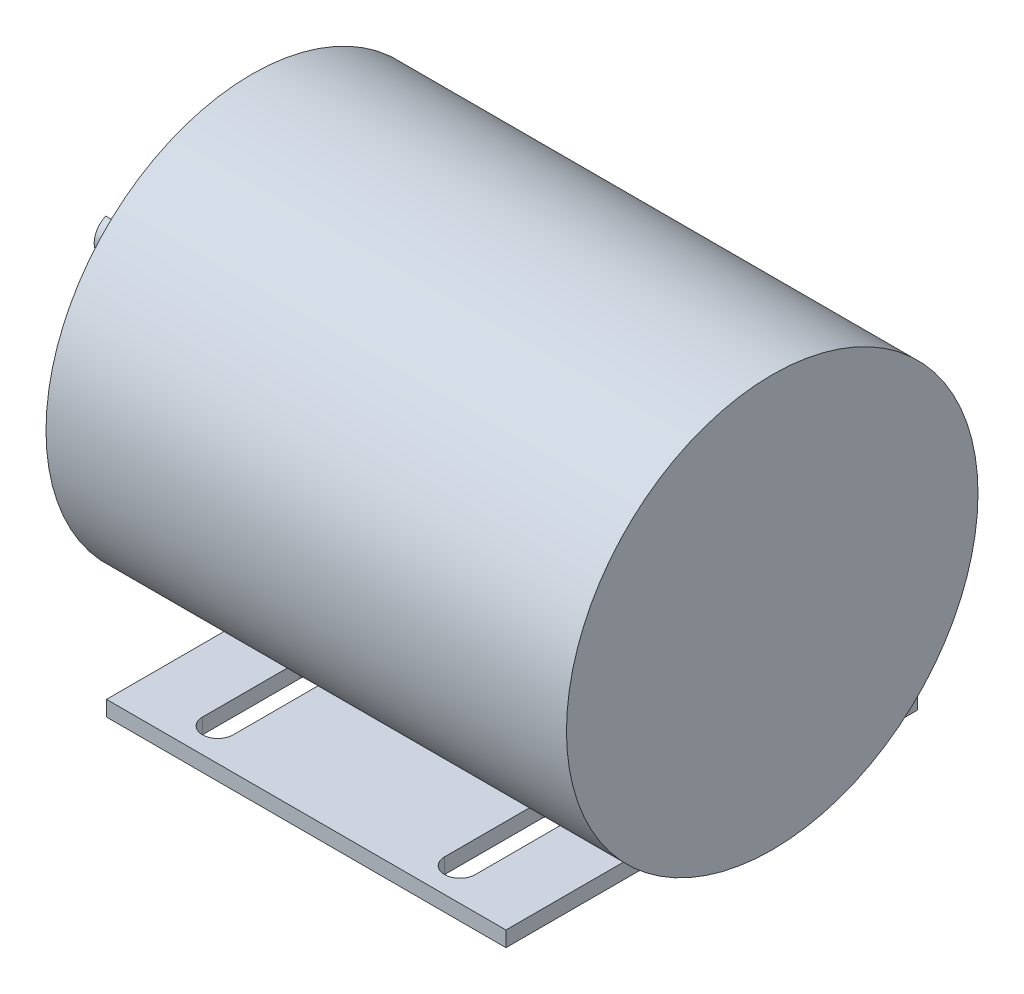
from build123d import *

# Parameters (mm, degrees)
CROQUIS1_R              = 85
SALIENTE_EXTRUIR1_DEPTH = 215
CROQUIS2_R              = 7.9375
SALIENTE_EXTRUIR2_DEPTH = 57.15
CROQUIS4_W              = 165
CROQUIS4_H              = 170
SALIENTE_EXTRUIR3_DEPTH = 6.35
CORTAR_EXTRUIR1_DEPTH   = 25
CORTAR_EXTRUIR2_DEPTH   = 10


with BuildPart() as part:
    # Croquis1 → Saliente-Extruir1 (new body)
    with BuildSketch(Plane(origin=(0, 0, 0), x_dir=(0, 0, -1), z_dir=(1, 0, 0))):
        Circle(CROQUIS1_R)
    extrude(amount=SALIENTE_EXTRUIR1_DEPTH)

    # Croquis2 → Saliente-Extruir2 (add)
    with BuildSketch(Plane.ZY):
        Circle(CROQUIS2_R)
    extrude(amount=SALIENTE_EXTRUIR2_DEPTH)

    # Croquis4 → Saliente-Extruir3 (add)
    with BuildSketch(Plane(origin=(0, -90, 0), x_dir=(1, 0, 0), z_dir=(0, 1, 0))):
        with Locations((107.5, 0)):
            Rectangle(CROQUIS4_W, CROQUIS4_H)
    extrude(amount=SALIENTE_EXTRUIR3_DEPTH)

    # Croquis5 → Cortar-Extruir1 (cut)
    with BuildSketch(Plane.ZY.offset(57.15)):
        with BuildLine():
            Line((-3.175, 7.274838916), (-3.175, 4.7625))
            Line((-3.175, 4.7625), (3.175, 4.7625))
            Line((3.175, 4.7625), (3.175, 7.274838916))
            ThreePointArc((3.175, 7.274838916), (0, 7.9375), (-3.175, 7.274838916))
        make_face()
    extrude(amount=-CORTAR_EXTRUIR1_DEPTH, mode=Mode.SUBTRACT)

    # Croquis7 → Cortar-Extruir2 (cut)
    with BuildSketch(Plane.XZ.offset(90)):
        with BuildLine():
            Line((51.15, 71.515151515), (51.15, 31.515151515))
            ThreePointArc((51.15, 31.515151515), (57.5, 25.165151515), (63.85, 31.515151515))
            Line((63.85, 31.515151515), (63.85, 71.515151515))
            ThreePointArc((63.85, 71.515151515), (57.5, 77.865151515), (51.15, 71.515151515))
        make_face()
        with BuildLine():
            Line((151.15, 71.515151515), (151.15, 31.515151515))
            ThreePointArc((151.15, 31.515151515), (157.5, 25.165151515), (163.85, 31.515151515))
            Line((163.85, 31.515151515), (163.85, 71.515151515))
            ThreePointArc((163.85, 71.515151515), (157.5, 77.865151515), (151.15, 71.515151515))
        make_face()
        with BuildLine():
            Line((51.15, -31.515151515), (51.15, -71.515151515))
            ThreePointArc((51.15, -71.515151515), (57.5, -77.865151515), (63.85, -71.515151515))
            Line((63.85, -71.515151515), (63.85, -31.515151515))
            ThreePointArc((63.85, -31.515151515), (57.5, -25.165151515), (51.15, -31.515151515))
        make_face()
        with BuildLine():
            Line((151.15, -31.515151515), (151.15, -71.515151515))
            ThreePointArc((151.15, -71.515151515), (157.5, -77.865151515), (163.85, -71.515151515))
            Line((163.85, -71.515151515), (163.85, -31.515151515))
            ThreePointArc((163.85, -31.515151515), (157.5, -25.165151515), (151.15, -31.515151515))
        make_face()
    extrude(amount=-CORTAR_EXTRUIR2_DEPTH, mode=Mode.SUBTRACT)


solid = part.part
